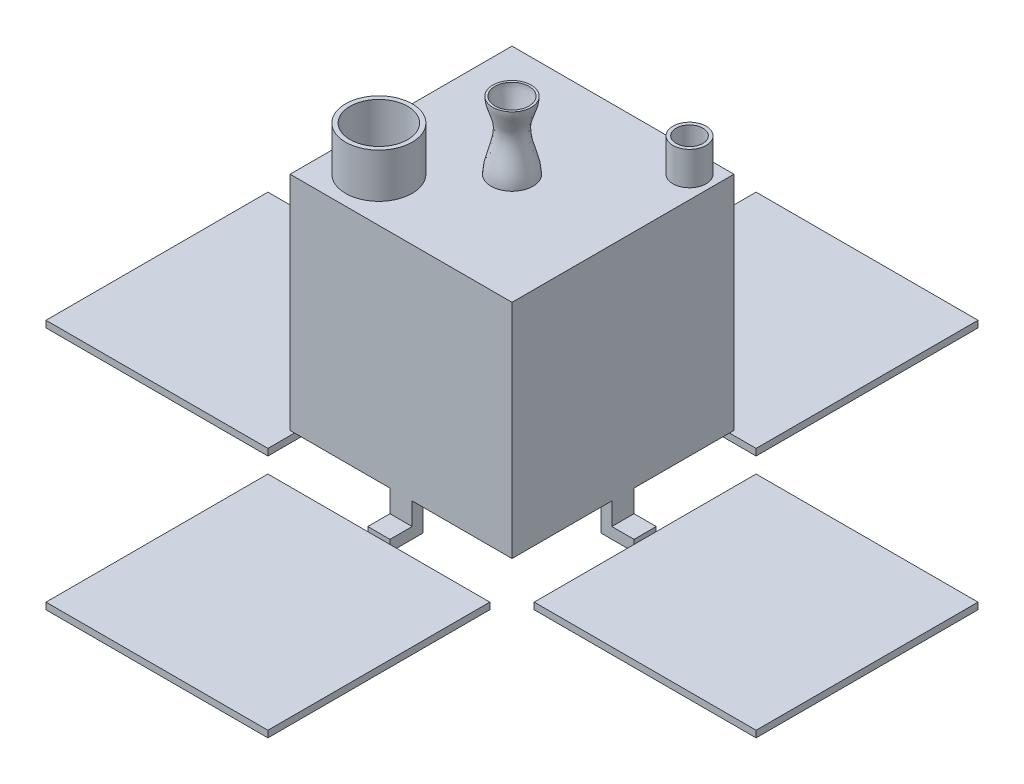
from build123d import *

# Parameters (mm, degrees)
SKETCH_1_W               = 100
SKETCH_1_H               = 100
EXTRUDE_1_DEPTH          = 100
EXTRUDE_2_DEPTH          = 5
SKETCH_4_W               = 100
SKETCH_4_H               = 100
EXTRUDE_3_DEPTH          = 3
PATTERN_CIRCULAR_1_COUNT = 4
SKETCH_7_R               = 15
SKETCH_7_R_2             = 13
EXTRUDE_5_DEPTH          = 20
SKETCH_8_R               = 7.5
SKETCH_8_R_2             = 6
EXTRUDE_6_DEPTH          = 15
SKETCH_11_R              = 7.210019968
CUT_EXTRUDE_2_DEPTH      = 5


with BuildPart() as part:
    # Эскиз1 → Бобышка-Вытянуть1 (new body)
    with BuildSketch(Plane(origin=(0, 0, 0), x_dir=(1, 0, 0), z_dir=(0, 1, 0))):
        Rectangle(SKETCH_1_W, SKETCH_1_H)
    extrude(amount=EXTRUDE_1_DEPTH)

    # Эскиз3 → Бобышка-Вытянуть2 (add, symmetric)
    with BuildSketch(Plane.XY):
        Polygon((60, -10), (60, -15), (45, -15), (45, 0), (50, 0), (50, -10), align=None)
    extrude_2 = extrude(amount=EXTRUDE_2_DEPTH, both=True)

    # Эскиз4 → Бобышка-Вытянуть3 (add)
    with BuildSketch(Plane.XZ.offset(15)):
        with Locations((110, 0)):
            Rectangle(SKETCH_4_W, SKETCH_4_H)
    extrude_3 = extrude(amount=-EXTRUDE_3_DEPTH)

    # Круговой массив1: Бобышка-Вытянуть2, Бобышка-Вытянуть3 ×4 about axis
    pattern_circular_1_axis = Axis((0, 0, 0), (0, 1, 0))
    for i in range(1, PATTERN_CIRCULAR_1_COUNT):
        add(extrude_2.rotate(pattern_circular_1_axis, i * 360 / PATTERN_CIRCULAR_1_COUNT))
        add(extrude_3.rotate(pattern_circular_1_axis, i * 360 / PATTERN_CIRCULAR_1_COUNT))

    # Эскиз7 → Бобышка-Вытянуть5 (add)
    with BuildSketch(Plane(origin=(0, 100, 0), x_dir=(1, 0, 0), z_dir=(0, 1, 0))):
        with Locations((-30, -30)):
            Circle(SKETCH_7_R)
        with Locations((-30, -30)):
            Circle(SKETCH_7_R_2, mode=Mode.SUBTRACT)
    extrude(amount=EXTRUDE_5_DEPTH)

    # Эскиз8 → Бобышка-Вытянуть6 (add)
    with BuildSketch(Plane(origin=(0, 100, 0), x_dir=(1, 0, 0), z_dir=(0, 1, 0))):
        with Locations((40, 40)):
            Circle(SKETCH_8_R)
        with Locations((40, 40)):
            Circle(SKETCH_8_R_2, mode=Mode.SUBTRACT)
    extrude(amount=EXTRUDE_6_DEPTH)

    # Эскиз10 → Повернуть1 (revolve)
    with BuildSketch(Plane.XY):
        with BuildLine():
            Line((8.680645457, 130.445795914), (7.680645457, 130.445795914))
            add(Edge.make_bspline(
                [(7.680645457, 130.445795914), (7.680645457, 127.036197798), (1.669418546, 117.303060729), (8.436480148, 106.717484225), (8.436480148, 100)],
                knots=[0, 0, 0, 0, 0.331036339, 1, 1, 1, 1], degree=3))
            Line((8.436480148, 100), (9.436480148, 100))
            add(Edge.make_bspline(
                [(8.680645457, 130.445795914), (8.680645457, 129.743031745), (8.522630114, 128.322957752), (7.990188694, 126.341389545), (7.322411145, 124.435424215), (6.663640941, 122.600134826), (6.143869676, 120.828668813), (5.810471482, 118.538078927), (6.008246237, 115.536453962), (6.892964845, 111.786431822), (8.442762115, 106.643818661), (9.436480148, 102.680139866), (9.436480148, 100)],
                knots=[0, 0, 0, 0, 0.0625, 0.125, 0.1875, 0.25, 0.3125, 0.375, 0.5, 0.625, 0.75, 1, 1, 1, 1], degree=3))
        make_face()
    revolve(axis=Axis((0, 100, 0), (0, 1, 0)))

    # Эскиз11 → Вырез-Вытянуть2 (cut)
    with BuildSketch(Plane.XZ):
        with Locations((-26.927393067, 25.615882257)):
            Circle(SKETCH_11_R)
    extrude(amount=-CUT_EXTRUDE_2_DEPTH, mode=Mode.SUBTRACT)


solid = part.part
